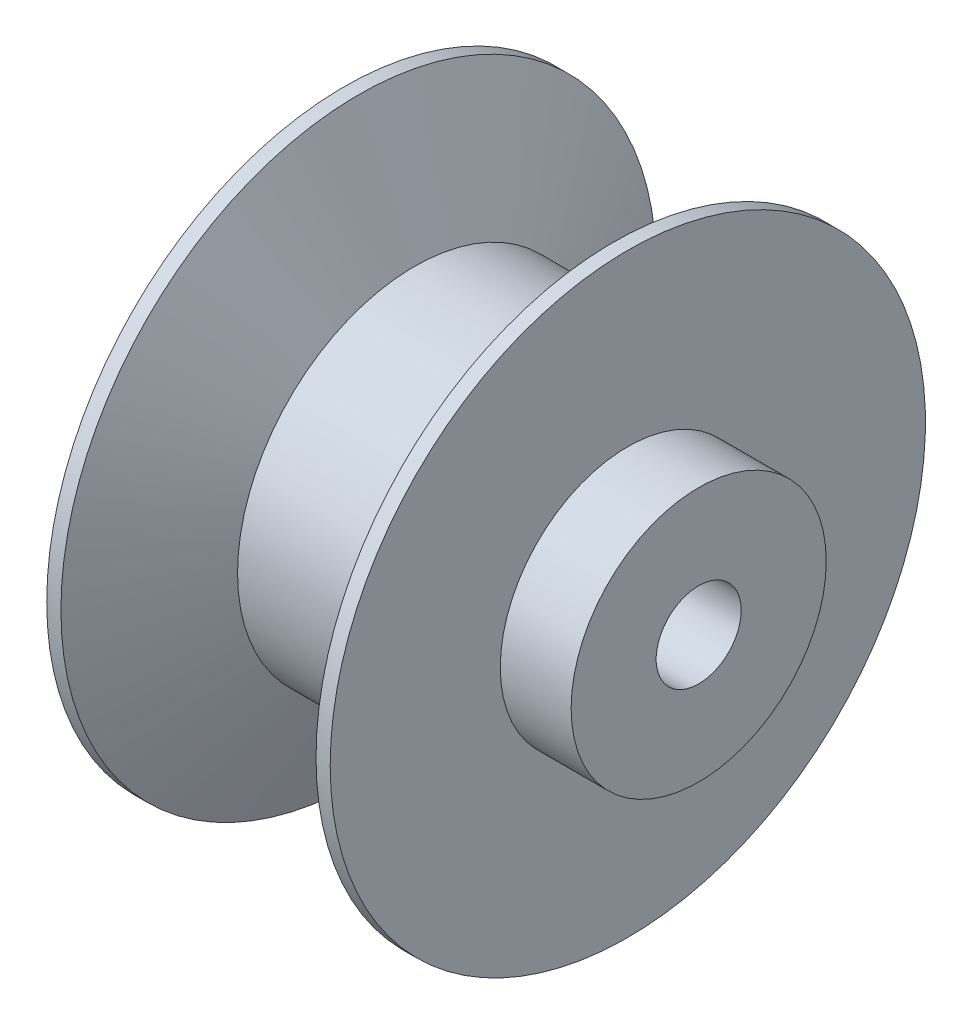
from build123d import *

# Parameters (mm, degrees)
ESQUISSE2_R             = 6
ENL_V_MAT_EXTRU_1_DEPTH = 40


with BuildPart() as part:
    # Esquisse1 → Révolution1 (revolve)
    with BuildSketch(Plane.XY, mode=Mode.PRIVATE) as r_volution1_sk:
        Polygon((-55.657677475, 42), (-53.657677475, 42), (-45.730447287, 25), (-25.584907664, 25), (-17.657677475, 42), (-15.657677475, 42), (-15.657677475, 18), (-5.657677475, 18), (-5.657677475, 3), (-65.657677475, 3), (-65.657677475, 18), (-55.657677475, 18), align=None)
    revolve(r_volution1_sk.sketch.rotate(Axis((-128.723358614, 0, 0), (1, 0, 0)), 90), axis=Axis((-128.723358614, 0, 0), (1, 0, 0)))  # turned: the seam where the file's is

    # Esquisse2 → Enlèv. mat.-Extru.1 (cut)
    with BuildSketch(Plane(origin=(-5.657677475, 0, 0), x_dir=(0, 0, -1), z_dir=(1, 0, 0))):
        Circle(ESQUISSE2_R)
    extrude(amount=-ENL_V_MAT_EXTRU_1_DEPTH, mode=Mode.SUBTRACT)


solid = part.part
